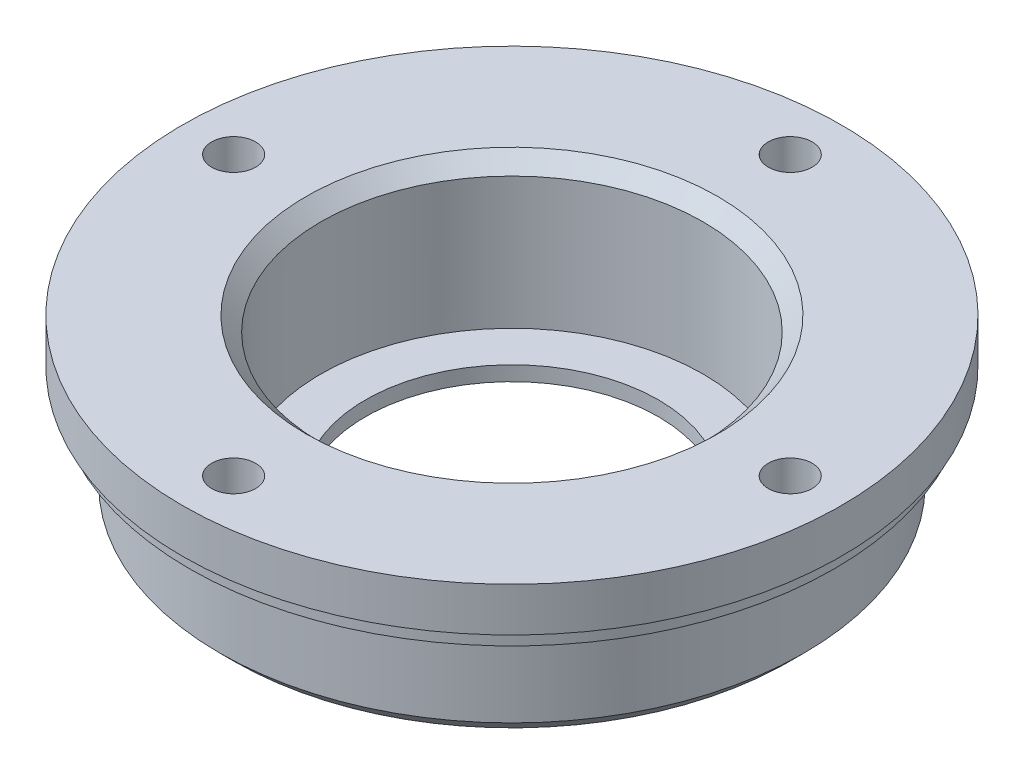
from build123d import *

# Parameters (mm, degrees)
SKETCH1_R           = 19.95
SKETCH1_R_2         = 13.05
BOSS_EXTRUDE1_DEPTH = 7
SKETCH2_R           = 13.05
SKETCH2_R_2         = 10
BOSS_EXTRUDE2_DEPTH = 1
SKETCH3_R           = 22
SKETCH3_R_2         = 13.05
BOSS_EXTRUDE3_DEPTH = 1
SKETCH4_R           = 22.5
SKETCH4_R_2         = 1.5
SKETCH4_R_3         = 13.05
BOSS_EXTRUDE7_DEPTH = 3
CHAMFER1_SIZE       = 1
SKETCH6_R           = 1.5
CUT_EXTRUDE1_DEPTH  = 1


with BuildPart() as part:
    # Sketch1 → Boss-Extrude1 (new body)
    with BuildSketch(Plane(origin=(0, 0, 0), x_dir=(1, 0, 0), z_dir=(0, 1, 0))):
        Circle(SKETCH1_R)
        Circle(SKETCH1_R_2, mode=Mode.SUBTRACT)
    extrude(amount=BOSS_EXTRUDE1_DEPTH)

    # Sketch2 → Boss-Extrude2 (add)
    with BuildSketch(Plane(origin=(0, 0, 0), x_dir=(-1, 0, 0), z_dir=(0, -1, 0))):
        Circle(SKETCH2_R)
        Circle(SKETCH2_R_2, mode=Mode.SUBTRACT)
    extrude(amount=-BOSS_EXTRUDE2_DEPTH)

    # Sketch3 → Boss-Extrude3 (add)
    with BuildSketch(Plane(origin=(0, 7, 0), x_dir=(1, 0, 0), z_dir=(0, 1, 0))):
        Circle(SKETCH3_R)
        Circle(SKETCH3_R_2, mode=Mode.SUBTRACT)
    extrude(amount=BOSS_EXTRUDE3_DEPTH)

    # Sketch4 → Boss-Extrude7 (add)
    with BuildSketch(Plane(origin=(0, 8, 0), x_dir=(1, 0, 0), z_dir=(0, 1, 0))):
        Circle(SKETCH4_R)
        with Locations((0, 19)):
            Circle(SKETCH4_R_2, mode=Mode.SUBTRACT)
        with Locations((19, 0)):
            Circle(SKETCH4_R_2, mode=Mode.SUBTRACT)
        with Locations((0, -19)):
            Circle(SKETCH4_R_2, mode=Mode.SUBTRACT)
        with Locations((-19, 0)):
            Circle(SKETCH4_R_2, mode=Mode.SUBTRACT)
        Circle(SKETCH4_R_3, mode=Mode.SUBTRACT)
    extrude(amount=BOSS_EXTRUDE7_DEPTH)

    # Chamfer1
    chamfer1_edges = [part.edges().sort_by_distance(p)[0] for p in [
        (-19.95, 0, 0),
        (-13.05, 11, 0),
    ]]
    chamfer(chamfer1_edges, length=CHAMFER1_SIZE)

    # Sketch6 → Cut-Extrude1 (cut)
    with BuildSketch(Plane(origin=(0, 8, 0), x_dir=(1, 0, 0), z_dir=(0, 1, 0))):
        with Locations((-19, 0)):
            Circle(SKETCH6_R)
        with Locations((0, -19)):
            Circle(SKETCH6_R)
        with Locations((19, 0)):
            Circle(SKETCH6_R)
        with Locations((0, 19)):
            Circle(SKETCH6_R)
    extrude(amount=-CUT_EXTRUDE1_DEPTH, mode=Mode.SUBTRACT)


solid = part.part
